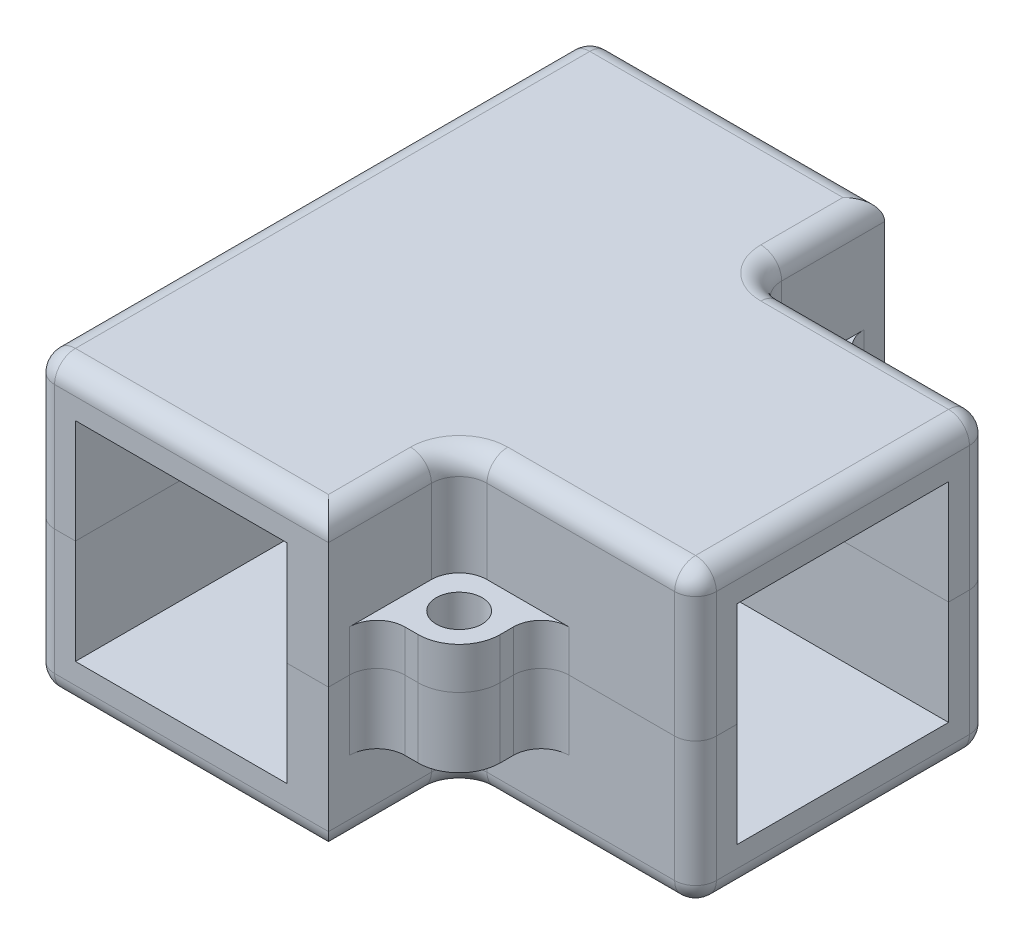
from build123d import *

# Parameters (mm, degrees)
BOSS_EXTRUDE1_DEPTH   = 7.5
BOSS_EXTRUDE1_2_DEPTH = 7.5
SKETCH3_W             = 3
SKETCH3_H             = 40
BOSS_EXTRUDE1_3_DEPTH = 7.5
BOSS_EXTRUDE2_DEPTH   = 3
SKETCH5_R             = 1.65
BOSS_EXTRUDE3_DEPTH   = 3
FILLET1_R             = 2
FILLET2_R             = 2
FILLET3_R             = 1.5
BOSS_EXTRUDE4_START   = -3
SKETCH6_R             = 1.65
BOSS_EXTRUDE4_DEPTH   = 3
MOVE_FACE1_BY         = 2
MOVE_FACE1_2_BY       = 2
MOVE_FACE1_3_BY       = 2
SKETCH7_R             = 2.1
CUT_EXTRUDE1_DEPTH    = 3


with BuildPart() as part:
    # Sketch3 → Boss-Extrude1 (new body)
    with BuildSketch(Plane(origin=(0, 0, 0), x_dir=(1, 0, 0), z_dir=(0, 1, 0))):
        Polygon((35.2, 27.6), (15.2, 27.6), (15.2, 40), (18.2, 40), (18.2, 30.6), (35.2, 30.6), align=None)
    extrude(amount=BOSS_EXTRUDE1_DEPTH)



with BuildPart() as body_2:
    # Sketch3 → Boss-Extrude1 2 (new body)
    with BuildSketch(Plane(origin=(0, 0, 0), x_dir=(1, 0, 0), z_dir=(0, 1, 0))):
        Polygon((18.2, 9.4), (35.2, 9.4), (35.2, 12.4), (15.2, 12.4), (15.2, 0), (18.2, 0), align=None)
    extrude(amount=BOSS_EXTRUDE1_2_DEPTH)


with BuildPart() as body_3:
    # Sketch3 → Boss-Extrude1 3 (new body)
    with BuildSketch(Plane(origin=(0, 0, 0), x_dir=(1, 0, 0), z_dir=(0, 1, 0))):
        with Locations((-1.5, 20)):
            Rectangle(SKETCH3_W, SKETCH3_H)
    extrude(amount=BOSS_EXTRUDE1_3_DEPTH)


with BuildPart() as part_1:
    add(part.part)

    add(body_2.part)  # Boss-Extrude2 merges body 2

    add(body_3.part)  # Boss-Extrude2 merges body 3
    # Sketch4 → Boss-Extrude2 (add)
    with BuildSketch(Plane(origin=(0, 7.5, 0), x_dir=(1, 0, 0), z_dir=(0, 1, 0))):
        Polygon((-3, 40), (-3, 0), (18.2, 0), (18.2, 9.4), (35.2, 9.4), (35.2, 30.6), (18.2, 30.6), (18.2, 40), align=None)
    extrude(amount=BOSS_EXTRUDE2_DEPTH)

    # Sketch5 → Boss-Extrude3 (add)
    with BuildSketch(Plane(origin=(0, 0, 0), x_dir=(1, 0, 0), z_dir=(0, 1, 0))):
        with BuildLine():
            Line((21.15, 36.5), (18.2, 36.5))
            Line((18.2, 36.5), (18.2, 30.6))
            Line((18.2, 30.6), (24.1, 30.6))
            Line((24.1, 30.6), (24.1, 33.55))
            ThreePointArc((24.1, 33.55), (23.235965005, 35.635965005), (21.15, 36.5))
        make_face()
        with Locations(Location((21.15, 33.55, 0), (0, 0, 270))):
            Circle(SKETCH5_R, mode=Mode.SUBTRACT)
        with BuildLine():
            Line((24.1, 9.4), (24.1, 6.45))
            ThreePointArc((24.1, 6.45), (23.235965005, 4.364034995), (21.15, 3.5))
            Line((21.15, 3.5), (18.2, 3.5))
            Line((18.2, 3.5), (18.2, 9.4))
            Line((18.2, 9.4), (24.1, 9.4))
        make_face()
        with Locations(Location((21.15, 6.45, 0), (0, 0, 90))):
            Circle(SKETCH5_R, mode=Mode.SUBTRACT)
        with BuildLine():
            Line((-5.95, 22.95), (-3, 22.95))
            Line((-3, 22.95), (-3, 17.05))
            Line((-3, 17.05), (-5.95, 17.05))
            ThreePointArc((-5.95, 17.05), (-8.9, 20), (-5.95, 22.95))
        make_face()
        with Locations(Location((-5.95, 20, 0), (0, 0, 270))):
            Circle(SKETCH5_R, mode=Mode.SUBTRACT)
    extrude(amount=BOSS_EXTRUDE3_DEPTH)

    # Fillet1
    fillet1_edges = [part_1.edges().sort_by_distance(p)[0] for p in [
        (18.2, 6.75, -30.6),
        (18.2, 6.75, -9.4),
    ]]
    fillet(fillet1_edges, radius=FILLET1_R)

    # Fillet2
    fillet2_edges = [part_1.edges().sort_by_distance(p)[0] for p in [
        (18.2, 1.5, -36.5),
        (24.1, 1.5, -30.6),
        (-3, 1.5, -17.05),
        (-3, 1.5, -22.95),
        (24.1, 1.5, -9.4),
        (18.2, 1.5, -3.5),
    ]]
    fillet(fillet2_edges, radius=FILLET2_R)

    # Fillet3
    fillet3_edges = [part_1.edges().sort_by_distance(p)[0] for p in [
        (35.2, 5.25, -30.6),
        (27.7, 10.5, -9.4),
        (18.2, 10.5, -36.3),
        (18.785786438, 10.5, -8.814213562),
        (18.785786438, 10.5, -31.185786438),
        (-3, 5.25, -40),
        (-3, 5.25, 0),
        (35.2, 5.25, -9.4),
        (7.6, 10.5, -40),
        (-3, 10.5, -20),
        (7.6, 10.5, 0),
        (18.2, 10.5, -3.7),
        (35.2, 10.5, -20),
        (27.7, 10.5, -30.6),
    ]]
    fillet(fillet3_edges, radius=FILLET3_R)


with BuildPart() as body_2_2:
    # Mirror1: mirrored copy
    add(part_1.part.mirror(Plane(origin=(0, 0, 0), x_dir=(0, 0, 1), z_dir=(0, -1, 0))))

    # Sketch6 → Boss-Extrude4 (add)
    with BuildSketch(Plane(origin=(0, 0, 0), x_dir=(1, 0, 0), z_dir=(0, 1, 0)).offset(BOSS_EXTRUDE4_START)):
        with Locations(Location((21.15, 6.45, 0), (0, 0, 90))):
            Circle(SKETCH6_R)
        with Locations(Location((21.15, 33.55, 0), (0, 0, 270))):
            Circle(SKETCH6_R)
        with Locations(Location((-5.95, 20, 0), (0, 0, 270))):
            Circle(SKETCH6_R)
    extrude(amount=BOSS_EXTRUDE4_DEPTH)

    # Move Face1: a face moved outward by 2.0
    extrude(body_2_2.faces().sort_by_distance((21.109677146, -3, -33.509677146))[0], amount=MOVE_FACE1_BY, dir=(0, -1, 0))

    # Move Face1 2: a face moved outward by 2.0
    extrude(body_2_2.faces().sort_by_distance((21.109677146, -3, -6.490322854))[0], amount=MOVE_FACE1_2_BY, dir=(0, -1, 0))

    # Move Face1 3: a face moved outward by 2.0
    extrude(body_2_2.faces().sort_by_distance((-5.557976688, -3, -20))[0], amount=MOVE_FACE1_3_BY, dir=(0, -1, 0))

    # Sketch7 → Cut-Extrude1 (cut)
    with BuildSketch(Plane(origin=(0, 0, 0), x_dir=(1, 0, 0), z_dir=(0, 1, 0))):
        with Locations(Location((-5.95, 20, 0), (0, 0, 270))):
            Circle(SKETCH7_R)
        with Locations(Location((21.15, 33.55, 0), (0, 0, 270))):
            Circle(SKETCH7_R)
        with Locations(Location((21.15, 6.45, 0), (0, 0, 270))):
            Circle(SKETCH7_R)
    extrude(amount=-CUT_EXTRUDE1_DEPTH, mode=Mode.SUBTRACT)


solid = Compound([part_1.part, body_2_2.part])
